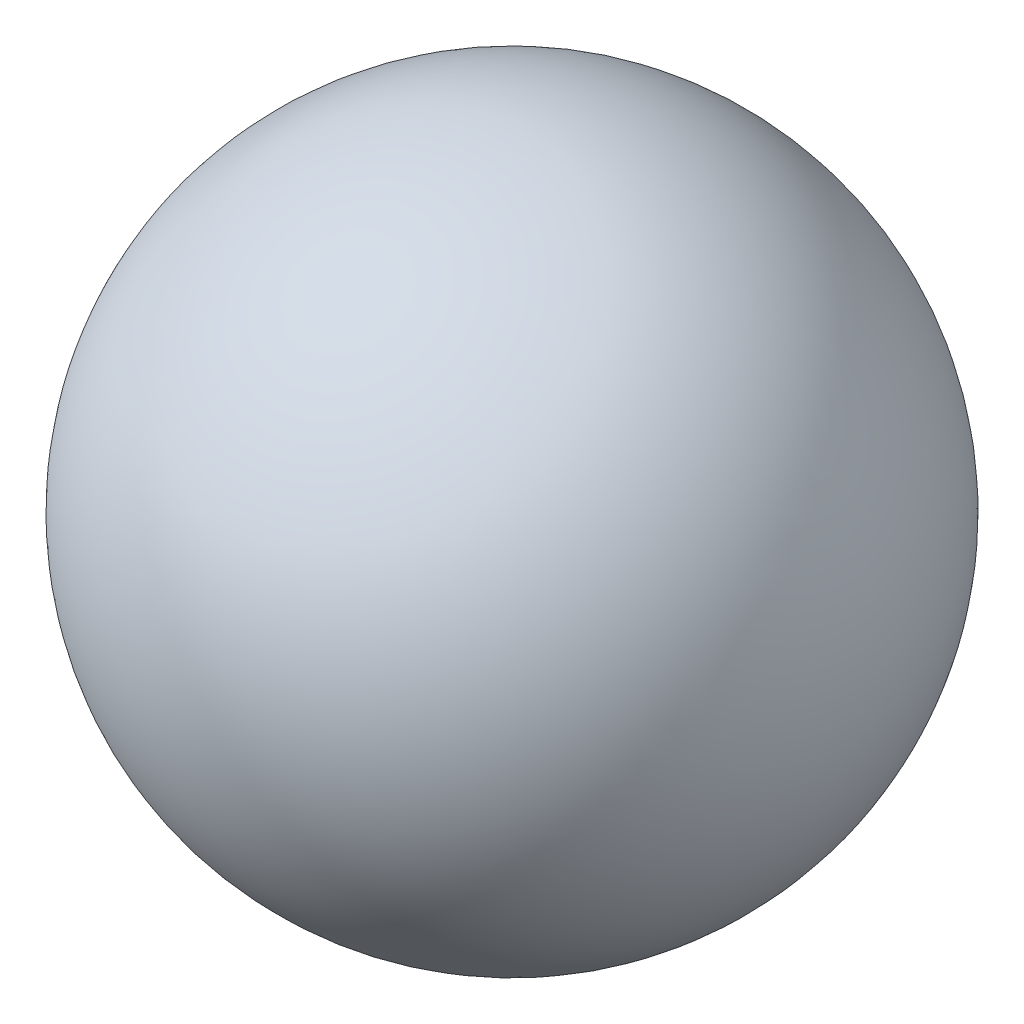
from build123d import *


with BuildPart() as part:
    # Sketch1 → Revolve1 (revolve)
    with BuildSketch(Plane(origin=(0, 0, 0), x_dir=(1, 0, 0), z_dir=(0, 1, 0))):
        with BuildLine():
            Line((-1.5, 0), (1.5, 0))
            ThreePointArc((1.5, 0), (0, 1.5), (-1.5, 0))
        make_face()
    revolve(axis=Axis((-1.5, 0, 0), (1, 0, 0)))


solid = part.part
